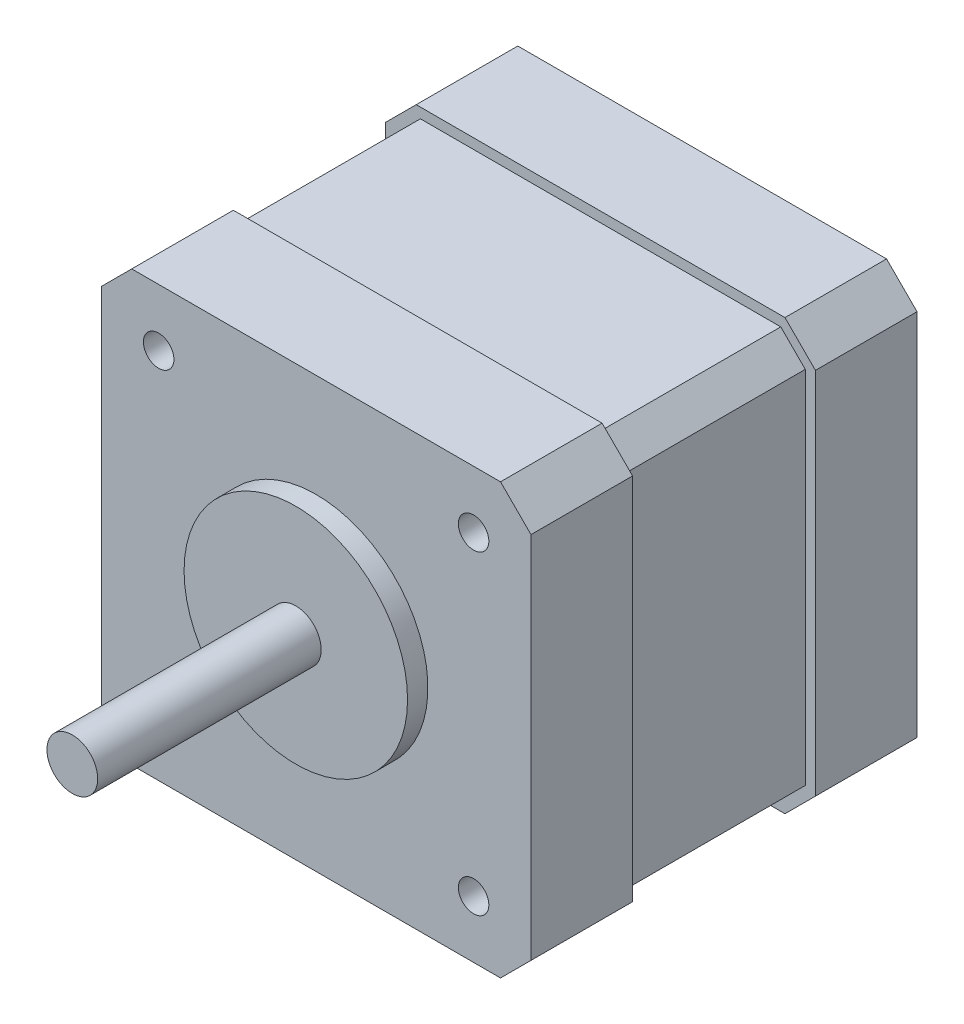
from build123d import *

# Parameters (mm, degrees)
EXTRUDE_1_DEPTH     = 10
SKETCH_2_R          = 11
EXTRUDE_2_DEPTH     = 2
SKETCH_3_R          = 2.5
EXTRUDE_3_DEPTH     = 22
EXTRUDE_4_DEPTH     = 18
EXTRUDE_5_DEPTH     = 10
SKETCH_4_R          = 1.5
CUT_EXTRUDE_1_DEPTH = 46.5
SKETCH_5_R          = 2.5
CUT_EXTRUDE_2_DEPTH = 1


with BuildPart() as part:
    # Эскиз1 → Бобышка-Вытянуть1 (new body)
    with BuildSketch(Plane.XY):
        Polygon((-32.767753805, -16.536194896), (-32.767753805, 19.763805104), (-29.767753805, 22.763805104), (6.532246195, 22.763805104), (9.532246195, 19.763805104), (9.532246195, -16.536194896), (6.532246195, -19.536194896), (-29.767753805, -19.536194896), align=None)
    extrude(amount=EXTRUDE_1_DEPTH)

    # Эскиз2 → Бобышка-Вытянуть2 (add)
    with BuildSketch(Plane.XY.offset(10)):
        with Locations((-11.617753805, 1.613805104)):
            Circle(SKETCH_2_R)
    extrude(amount=EXTRUDE_2_DEPTH)

    # Эскиз3 → Бобышка-Вытянуть3 (add)
    with BuildSketch(Plane.XY.offset(12)):
        with Locations((-11.617753805, 1.613805104)):
            Circle(SKETCH_3_R)
    extrude(amount=EXTRUDE_3_DEPTH)

    # Эскиз6 → Бобышка-Вытянуть4 (add)
    with BuildSketch(Plane(origin=(0, 0, 0), x_dir=(-1, 0, 0), z_dir=(0, 0, -1))):
        Polygon((11.617753805, 21.763805104), (-6.118032632, 21.763805104), (-8.532246195, 19.349591542), (-8.532246195, -16.121981333), (-6.118032632, -18.536194896), (29.353540243, -18.536194896), (31.767753805, -16.121981333), (31.767753805, 19.349591542), (29.353540243, 21.763805104), align=None)
    extrude(amount=EXTRUDE_4_DEPTH)

    # Эскиз7 → Бобышка-Вытянуть5 (add)
    with BuildSketch(Plane.XY.offset(-18)):
        Polygon((-32.767753805, -16.536194896), (-32.767753805, 19.763805104), (-29.767753805, 22.763805104), (6.532246195, 22.763805104), (9.532246195, 19.763805104), (9.532246195, -16.536194896), (6.532246195, -19.536194896), (-29.767753805, -19.536194896), align=None)
    extrude(amount=-EXTRUDE_5_DEPTH)

    # Эскиз4 → Вырез-Вытянуть1 (cut)
    with BuildSketch(Plane.XY.offset(10)):
        with Locations((-27.117753805, 17.113805104)):
            Circle(SKETCH_4_R)
        with Locations((3.882246195, 17.113805104)):
            Circle(SKETCH_4_R)
        with Locations((3.882246195, -13.886194896)):
            Circle(SKETCH_4_R)
        with Locations((-27.117753805, -13.886194896)):
            Circle(SKETCH_4_R)
    extrude(amount=-CUT_EXTRUDE_1_DEPTH, mode=Mode.SUBTRACT)

    # Эскиз5 → Вырез-Вытянуть2 (cut)
    with BuildSketch(Plane(origin=(0, 0, -28), x_dir=(-1, 0, 0), z_dir=(0, 0, -1))):
        with Locations((11.617753805, 1.613805104)):
            Circle(SKETCH_5_R)
    extrude(amount=-CUT_EXTRUDE_2_DEPTH, mode=Mode.SUBTRACT)


solid = part.part
